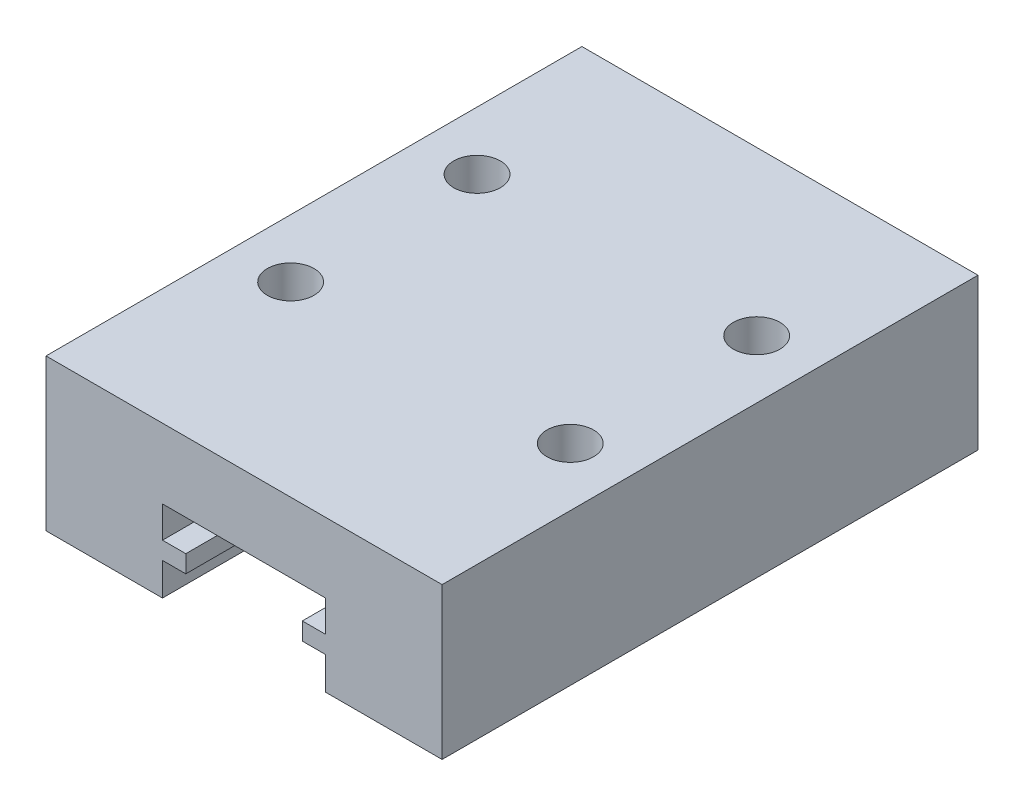
from build123d import *

# Parameters (mm, degrees)
EXTRUDE_1_DEPTH     = 23
CUT_EXTRUDE_START   = 3.25
SKETCH_2_R          = 1
CUT_EXTRUDE_1_DEPTH = 3


with BuildPart() as part:
    # 草图1 → 凸台-拉伸1 (new body)
    with BuildSketch(Plane.XY):
        Polygon((3.5, -1.85), (3.5, -3.25), (8.5, -3.25), (8.5, 3.25), (-8.5, 3.25), (-8.5, -3.25), (-3.5, -3.25), (-3.5, -1.85), (-2.5, -1.85), (-2.5, -1.1), (-3.5, -1.1), (-3.5, 0.25), (3.5, 0.25), (3.5, -1.1), (2.5, -1.1), (2.5, -1.85), align=None)
    extrude(amount=EXTRUDE_1_DEPTH)

    # 草图2 → 切除-拉伸1 (cut)
    with BuildSketch(Plane(origin=(0, 0, 0), x_dir=(1, 0, 0), z_dir=(0, 1, 0)).offset(CUT_EXTRUDE_START)):
        with Locations((-6, -7)):
            Circle(SKETCH_2_R)
        with Locations((6, -7)):
            Circle(SKETCH_2_R)
        with Locations((-6, -15)):
            Circle(SKETCH_2_R)
        with Locations((6, -15)):
            Circle(SKETCH_2_R)
    extrude(amount=-CUT_EXTRUDE_1_DEPTH, mode=Mode.SUBTRACT)


solid = part.part
